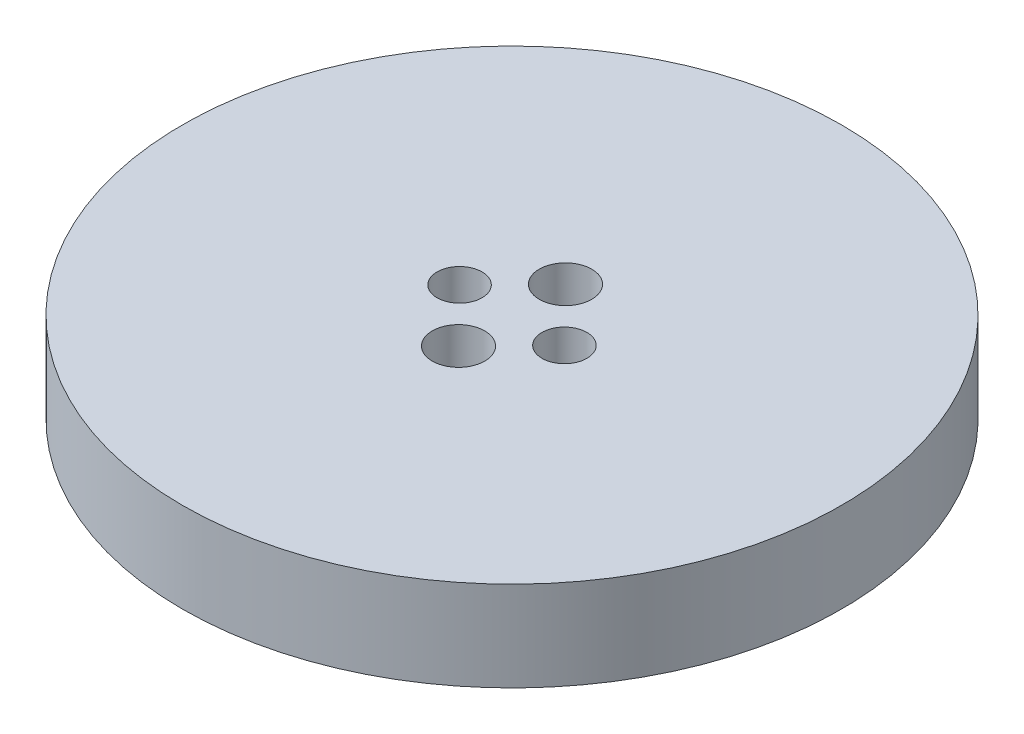
from build123d import *

# Parameters (mm, degrees)
ESQUISSE1_R        = 22
ESQUISSE1_R_2      = 1.5
ESQUISSE1_R_3      = 1.75
BOSS_EXTRU_1_DEPTH = 6


with BuildPart() as part:
    # Esquisse1 → Boss.-Extru.1 (new body)
    with BuildSketch(Plane(origin=(0, 0, 0), x_dir=(1, 0, 0), z_dir=(0, 1, 0))):
        Circle(ESQUISSE1_R)
        with Locations((-3.5, 0)):
            Circle(ESQUISSE1_R_2, mode=Mode.SUBTRACT)
        with Locations((3.5, 0)):
            Circle(ESQUISSE1_R_2, mode=Mode.SUBTRACT)
        with Locations((0, 3.570714214)):
            Circle(ESQUISSE1_R_3, mode=Mode.SUBTRACT)
        with Locations((0, -3.570714214)):
            Circle(ESQUISSE1_R_3, mode=Mode.SUBTRACT)
    extrude(amount=BOSS_EXTRU_1_DEPTH)


solid = part.part
